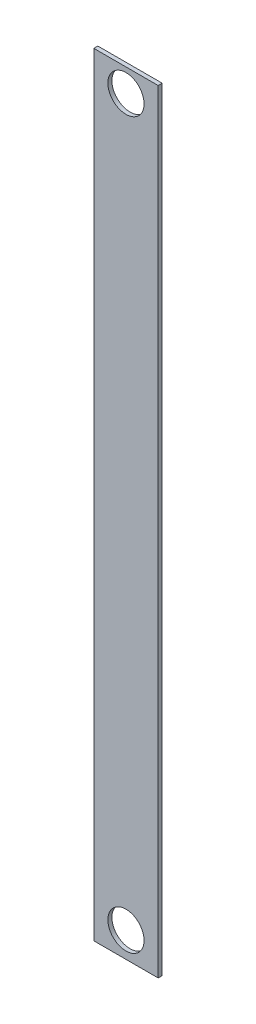
from build123d import *

# Parameters (mm, degrees)
SKETCH1_W           = 50.8
SKETCH1_H           = 609.6
BOSS_EXTRUDE1_DEPTH = 3.175
SKETCH2_R           = 14.279
CUT_EXTRUDE1_DEPTH  = 4.175


with BuildPart() as part:
    # Sketch1 → Boss-Extrude1 (new body)
    with BuildSketch(Plane.XY):
        with Locations((25.4, -304.8)):
            Rectangle(SKETCH1_W, SKETCH1_H)
    extrude(amount=BOSS_EXTRUDE1_DEPTH)

    # Sketch2 → Cut-Extrude1 (cut, through all)
    with BuildSketch(Plane.XY.offset(3.175)):
        with Locations((25.4, -18.141364063)):
            Circle(SKETCH2_R)
        with Locations((25.4, -589.6)):
            Circle(SKETCH2_R)
    extrude(amount=-CUT_EXTRUDE1_DEPTH, mode=Mode.SUBTRACT)


solid = part.part
